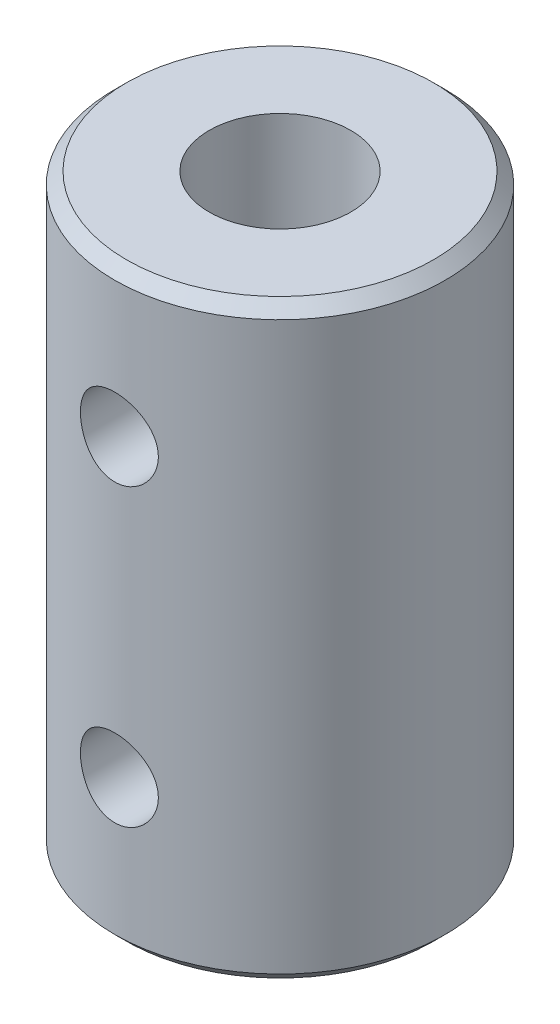
from build123d import *

# Parameters (mm, degrees)
CHAMFER1_SIZE          = 0.5
M4_TAPPED_HOLE1_REACH  = 31.496
M4_TAPPED_HOLE1_BORE_R = 1.65


with BuildPart() as part:
    # Sketch2 → Revolve1 (revolve)
    with BuildSketch(Plane(origin=(0, 0, 0), x_dir=(0, 0, -1), z_dir=(1, 0, 0))):
        Polygon((4, 0), (4, 12.5), (3, 12.5), (3, 25), (7, 25), (7, 0), align=None)
    revolve(axis=Axis((0, 0, 0), (0, 1, 0)))

    # Chamfer1
    chamfer1_edges = [part.edges().sort_by_distance(p)[0] for p in [
        (0, 0, 7),
        (0, 25, 7),
    ]]
    chamfer(chamfer1_edges, length=CHAMFER1_SIZE)

    # M4 Tapped Hole1 bore → M4 Tapped Hole1 (cut, up to next)
    with BuildSketch(Plane.XY.offset(7), mode=Mode.PRIVATE) as m4_tapped_hole1_sk1:
        with Locations((0, 18.75)):
            Circle(M4_TAPPED_HOLE1_BORE_R)
    m4_tapped_hole1_tool1 = extrude(m4_tapped_hole1_sk1.sketch, amount=-M4_TAPPED_HOLE1_REACH, mode=Mode.PRIVATE) & part.part
    # M4 Tapped Hole1 bore → M4 Tapped Hole1 (cut, up to next)
    with BuildSketch(Plane.XY.offset(7), mode=Mode.PRIVATE) as m4_tapped_hole1_sk2:
        with Locations((0, 6.25)):
            Circle(M4_TAPPED_HOLE1_BORE_R)
    m4_tapped_hole1_tool2 = extrude(m4_tapped_hole1_sk2.sketch, amount=-M4_TAPPED_HOLE1_REACH, mode=Mode.PRIVATE) & part.part
    add(m4_tapped_hole1_tool1.solids().sort_by_distance((0, 18.75, 7))[0], mode=Mode.SUBTRACT)
    add(m4_tapped_hole1_tool2.solids().sort_by_distance((0, 6.25, 7))[0], mode=Mode.SUBTRACT)


solid = part.part
